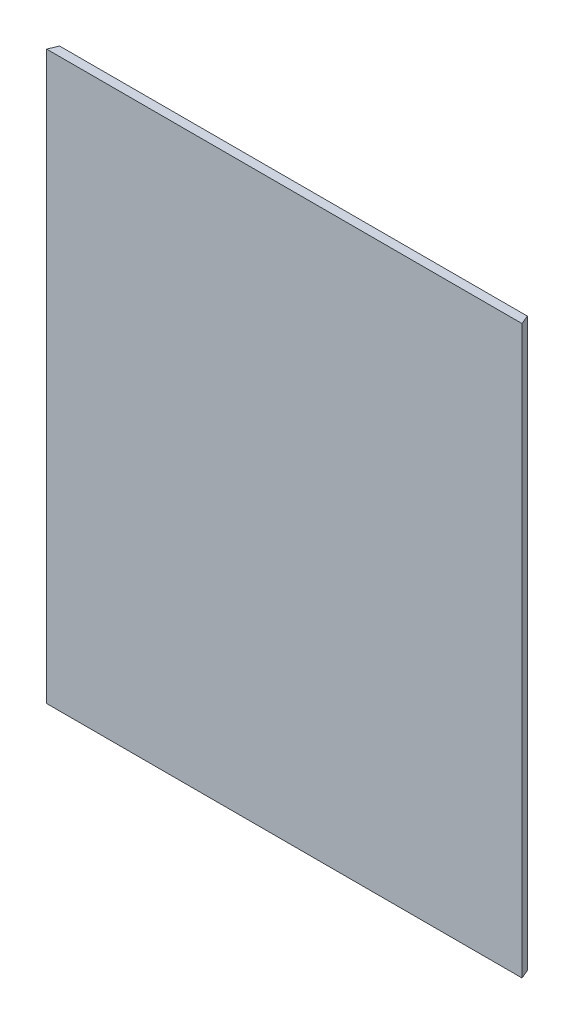
from build123d import *

# Parameters (mm, degrees)
ESQUISSE1_W        = 255.86
ESQUISSE1_H        = 310
BOSS_EXTRU_1_DEPTH = 5
BOSS_EXTRU_2_DEPTH = 310


with BuildPart() as part:
    # Esquisse1 → Boss.-Extru.1 (new body)
    with BuildSketch(Plane.XY):
        with Locations((127.93, 155)):
            Rectangle(ESQUISSE1_W, ESQUISSE1_H)
    extrude(amount=BOSS_EXTRU_1_DEPTH)

    # Esquisse2 → Boss.-Extru.2 (add)
    with BuildSketch(Plane(origin=(0, 310, 0), x_dir=(1, 0, 0), z_dir=(0, 1, 0))):
        Polygon((-2.07, -5), (257.93, -5), (255.86, 0), (0, 0), align=None)
    extrude(amount=-BOSS_EXTRU_2_DEPTH)


solid = part.part
